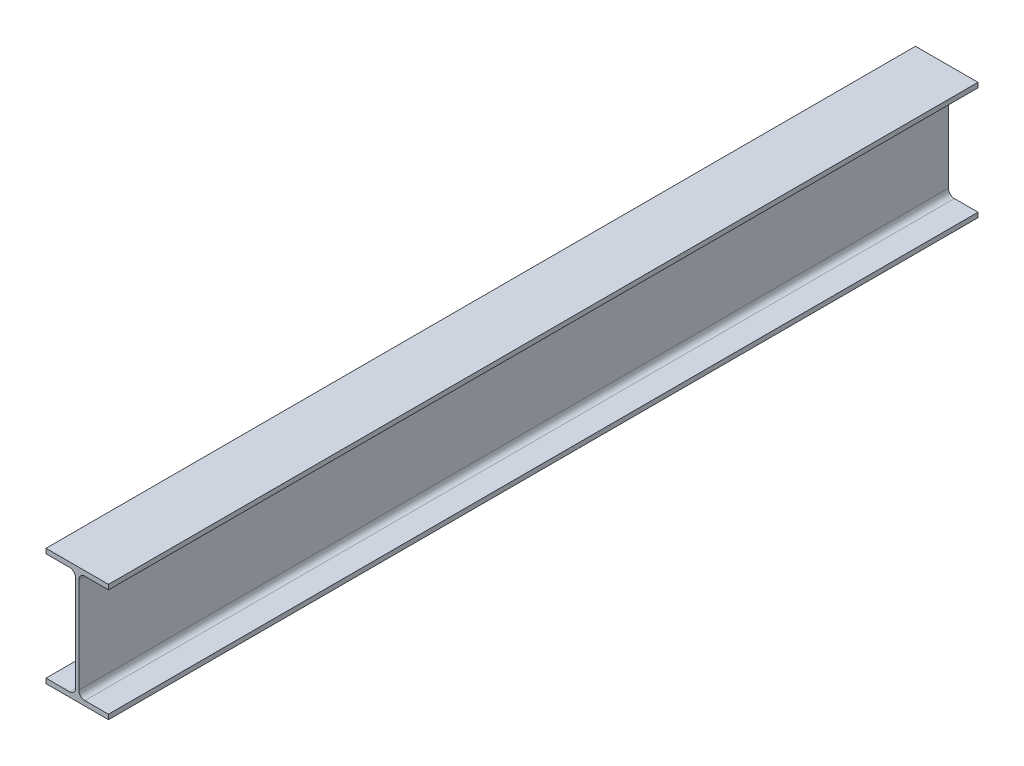
from build123d import *

# Parameters (mm, degrees)
BOSS_EXTRUDE1_DEPTH = 1016


with BuildPart() as part:
    # Sketch1 → Boss-Extrude1 (new body)
    with BuildSketch(Plane.XY):
        with BuildLine():
            Line((-36.5, 14.096450845), (36.5, 14.096450845))
            Line((36.5, 14.096450845), (36.5, 8.496450845))
            Line((36.5, 8.496450845), (8.9, 8.496450845))
            ThreePointArc((8.9, 8.496450845), (3.950252532, 6.446198313), (1.9, 1.496450845))
            Line((1.9, 1.496450845), (1.9, -110.303549155))
            ThreePointArc((1.9, -110.303549155), (3.950252532, -115.253296624), (8.9, -117.303549155))
            Line((8.9, -117.303549155), (36.5, -117.303549155))
            Line((36.5, -117.303549155), (36.5, -122.903549155))
            Line((36.5, -122.903549155), (-36.5, -122.903549155))
            Line((-36.5, -122.903549155), (-36.5, -117.303549155))
            Line((-36.5, -117.303549155), (-8.9, -117.303549155))
            ThreePointArc((-8.9, -117.303549155), (-3.950252532, -115.253296624), (-1.9, -110.303549155))
            Line((-1.9, -110.303549155), (-1.9, 1.496450845))
            ThreePointArc((-1.9, 1.496450845), (-3.950252532, 6.446198313), (-8.9, 8.496450845))
            Line((-8.9, 8.496450845), (-36.5, 8.496450845))
            Line((-36.5, 8.496450845), (-36.5, 14.096450845))
        make_face()
    extrude(amount=BOSS_EXTRUDE1_DEPTH)


solid = part.part
